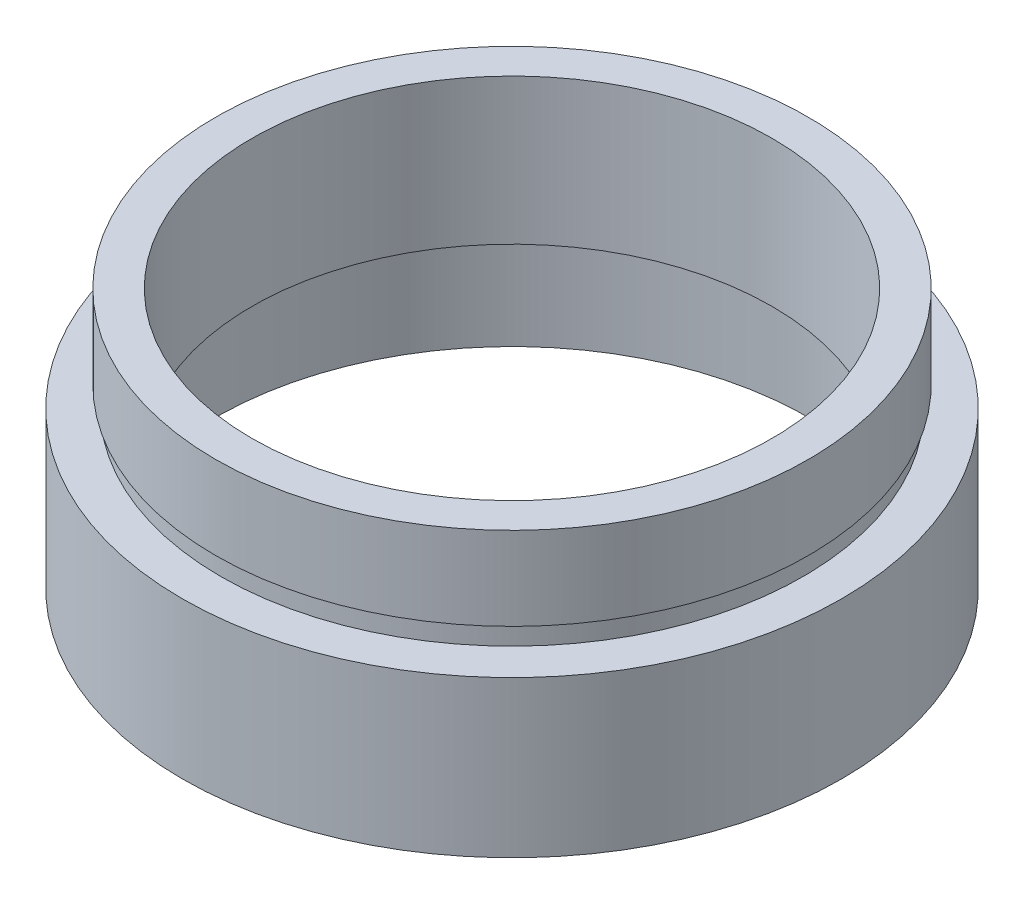
from build123d import *


with BuildPart() as part:
    # 草图1 → 旋转1 (revolve)
    with BuildSketch(Plane.XY, mode=Mode.PRIVATE) as revolve_1_sk:
        Polygon((14.25, 0), (14.25, 4.5), (14.35, 4.5), (14.35, 5.5), (12.5, 5.5), (12.5, 12.5), (14.25, 12.5), (14.25, 8.5), (14, 8.5), (14, 7.5), (15.85, 7.5), (15.85, 0), align=None)
    revolve(revolve_1_sk.sketch.rotate(Axis((0, 161.376166943, 0), (0, -1, 0)), 90), axis=Axis((0, 161.376166943, 0), (0, -1, 0)))  # turned: the seam where the file's is


solid = part.part
